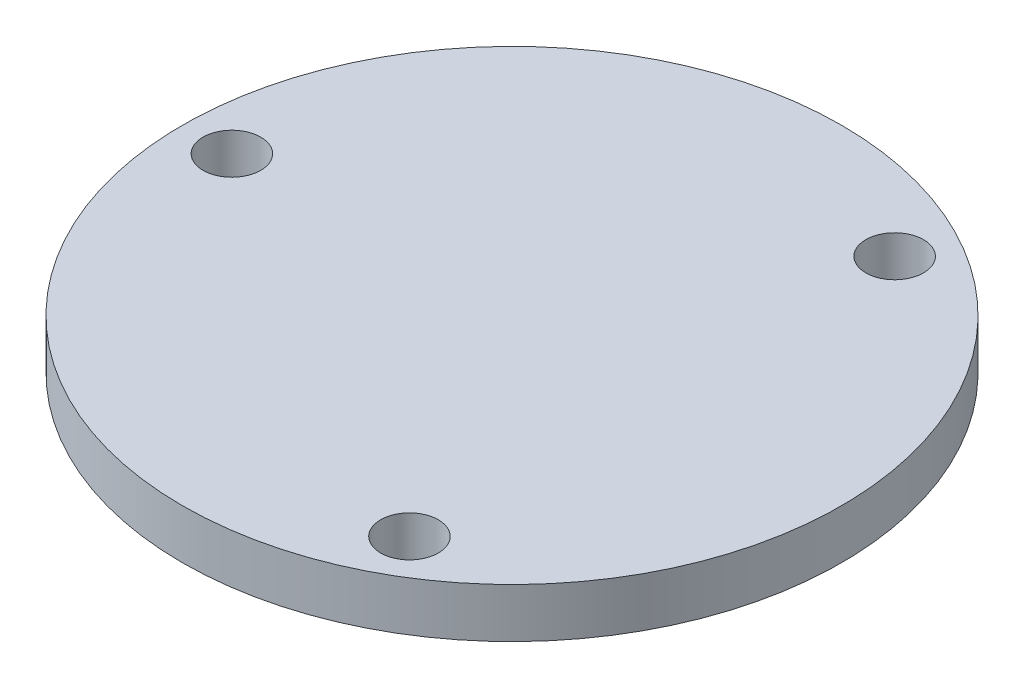
from build123d import *

# Parameters (mm, degrees)
SKETCH1_R           = 20
BOSS_EXTRUDE1_DEPTH = 3
CUT_EXTRUDE1_REACH  = 5
SKETCH2_R           = 1.75


with BuildPart() as part:
    # Sketch1 → Boss-Extrude1 (new body)
    with BuildSketch(Plane.XZ.offset(8)):
        with Locations((-34.143225555, 5.12970783)):
            Circle(SKETCH1_R)
    extrude(amount=BOSS_EXTRUDE1_DEPTH)

    # Sketch2 → Cut-Extrude1 (cut, up to next)
    with BuildSketch(Plane.XZ.offset(11), mode=Mode.PRIVATE) as cut_extrude1_sk1:
        with Locations((-51.143225555, 5.12970783)):
            Circle(SKETCH2_R)
    cut_extrude1_tool1 = extrude(cut_extrude1_sk1.sketch, amount=-CUT_EXTRUDE1_REACH, mode=Mode.PRIVATE) & part.part
    add(cut_extrude1_tool1.solids().sort_by_distance((-51.143226, -11, 5.129708))[0], mode=Mode.SUBTRACT)
    # Sketch2 → Cut-Extrude1 (cut, up to next)
    with BuildSketch(Plane.XZ.offset(11), mode=Mode.PRIVATE) as cut_extrude1_sk2:
        with Locations((-25.643225555, 19.852139695)):
            Circle(SKETCH2_R)
    cut_extrude1_tool2 = extrude(cut_extrude1_sk2.sketch, amount=-CUT_EXTRUDE1_REACH, mode=Mode.PRIVATE) & part.part
    add(cut_extrude1_tool2.solids().sort_by_distance((-25.643226, -11, 19.85214))[0], mode=Mode.SUBTRACT)
    # Sketch2 → Cut-Extrude1 (cut, up to next)
    with BuildSketch(Plane.XZ.offset(11), mode=Mode.PRIVATE) as cut_extrude1_sk3:
        with Locations((-25.643225555, -9.592724034)):
            Circle(SKETCH2_R)
    cut_extrude1_tool3 = extrude(cut_extrude1_sk3.sketch, amount=-CUT_EXTRUDE1_REACH, mode=Mode.PRIVATE) & part.part
    add(cut_extrude1_tool3.solids().sort_by_distance((-25.643226, -11, -9.592724))[0], mode=Mode.SUBTRACT)


solid = part.part
